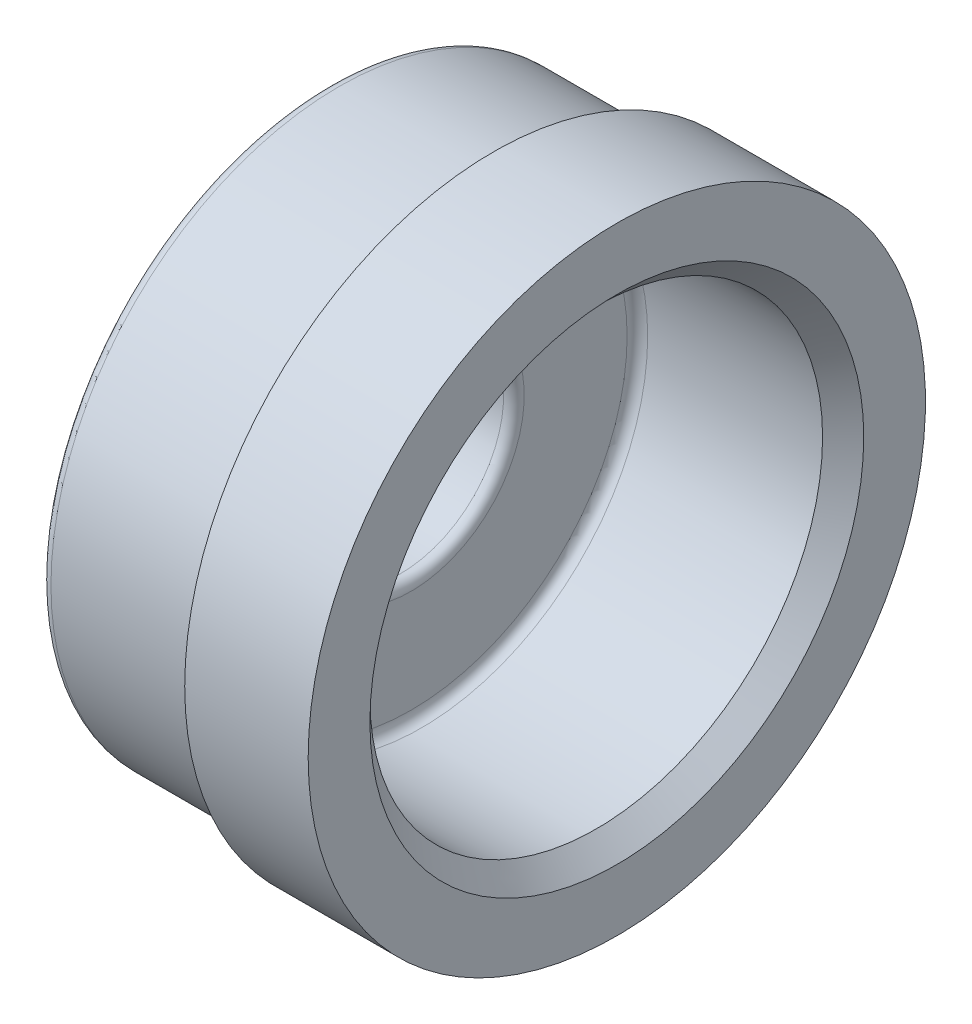
from build123d import *

# Parameters (mm, degrees)
REDONDEO1_R   = 0.5
CHAFL_N1_SIZE = 1


with BuildPart() as part:
    # Croquis1 → Revolución1 (revolve)
    with BuildSketch(Plane.XY):
        Polygon((0, 11), (10, 11), (10, 14), (10, 15), (4, 15), (4, 14), (-4, 14), (-4, 5), (0, 5), align=None)
    revolve(axis=Axis((-5.995381062, 0, 0), (1, 0, 0)))

    # Redondeo1
    redondeo1_edges = [part.edges().sort_by_distance(p)[0] for p in [
        (0, -11, 0),
        (0, -5, 0),
        (-4, -5, 0),
        (-4, -14, 0),
    ]]
    fillet(redondeo1_edges, radius=REDONDEO1_R)

    # Chaflán1
    chafl_n1_edges = [part.edges().sort_by_distance(p)[0] for p in [
        (10, -11, 0),
    ]]
    chamfer(chafl_n1_edges, length=CHAFL_N1_SIZE)


solid = part.part
